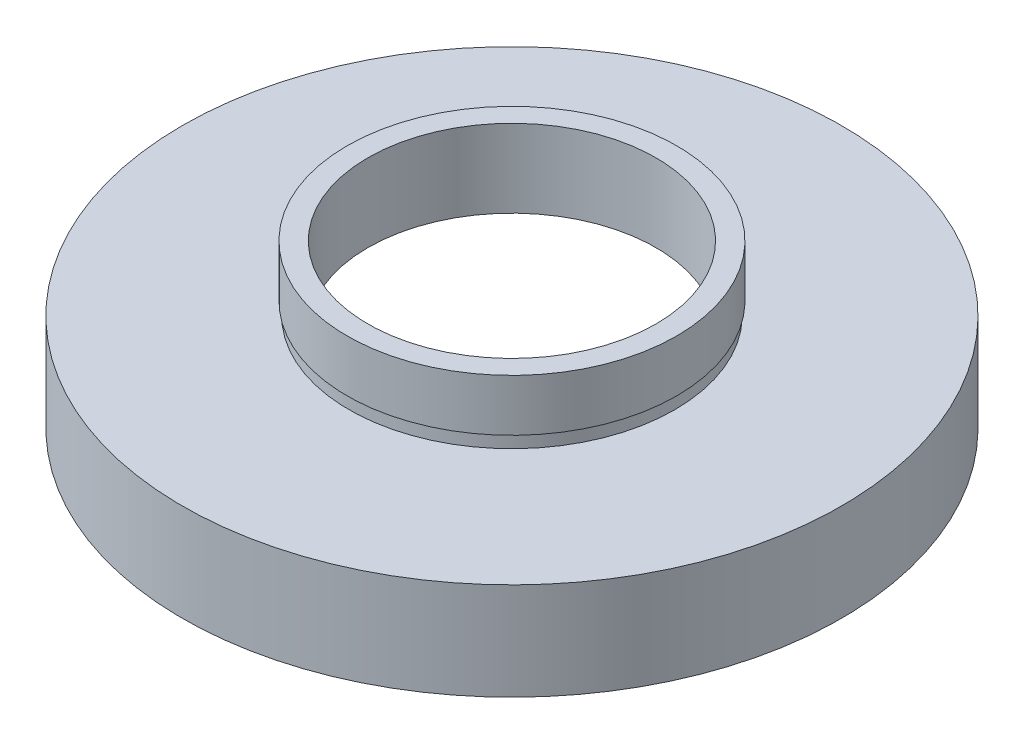
from build123d import *


with BuildPart() as part:
    # 草图1 → 旋转1 (revolve)
    with BuildSketch(Plane.XY, mode=Mode.PRIVATE) as revolve_1_sk:
        Polygon((20.5, 0), (20.5, 5.5), (21.1, 5.5), (21.1, 6.5), (11.1, 6.5), (11.1, 12.5), (12.7, 12.5), (12.7, 8.5), (12.55, 8.5), (12.55, 7.5), (25.4, 7.5), (25.4, 0), align=None)
    revolve(revolve_1_sk.sketch.rotate(Axis((0, 16.886018237, 0), (0, -1, 0)), 180), axis=Axis((0, 16.886018237, 0), (0, -1, 0)))  # turned: the seam where the file's is


solid = part.part
